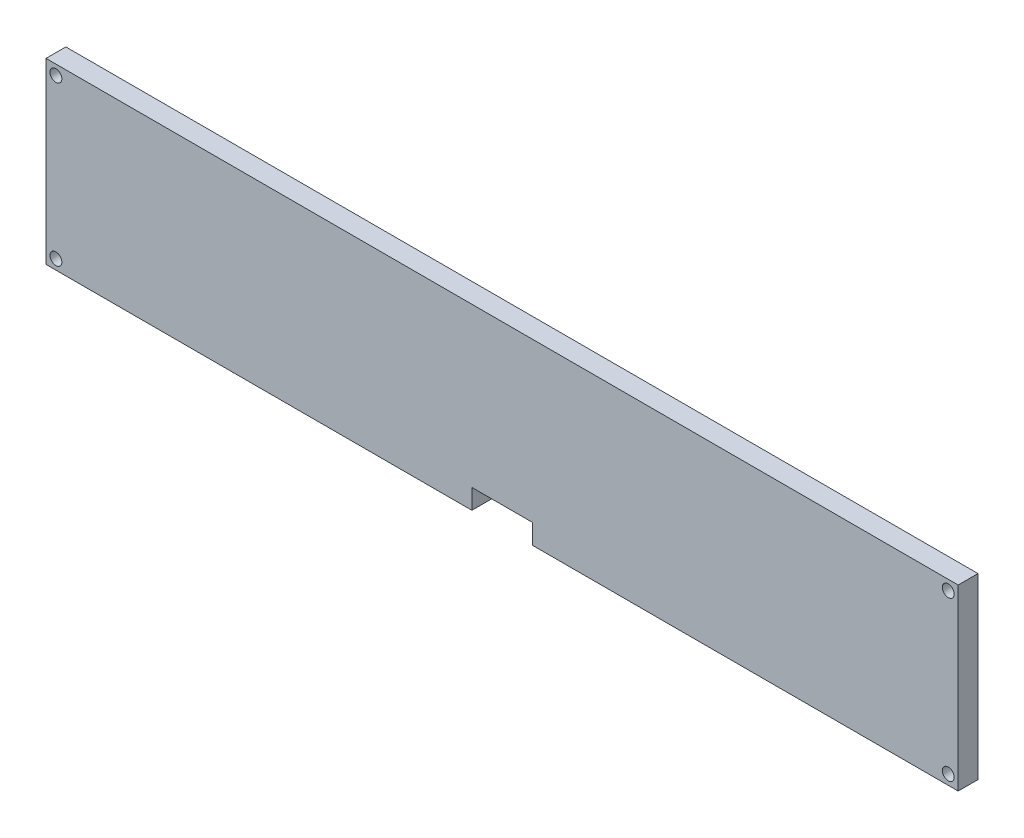
from build123d import *

# Parameters (mm, degrees)
SKETCH1_W           = 230
SKETCH1_H           = 45
BOSS_EXTRUDE1_DEPTH = 5
SKETCH2_R           = 1.5
CUT_EXTRUDE1_DEPTH  = 10
SKETCH3_W           = 15.24
SKETCH3_H           = 10
CUT_EXTRUDE2_DEPTH  = 5


with BuildPart() as part:
    # Sketch1 → Boss-Extrude1 (new body)
    with BuildSketch(Plane.XY):
        with Locations((115, 22.5)):
            Rectangle(SKETCH1_W, SKETCH1_H)
    extrude(amount=BOSS_EXTRUDE1_DEPTH)

    # Sketch2 → Cut-Extrude1 (cut)
    with BuildSketch(Plane(origin=(0, 0, 0), x_dir=(-1, 0, 0), z_dir=(0, 0, -1))):
        with Locations((-227.5, 42.5)):
            Circle(SKETCH2_R)
        with Locations((-227.5, 2.5)):
            Circle(SKETCH2_R)
        with Locations((-2.5, 2.5)):
            Circle(SKETCH2_R)
        with Locations((-2.5, 42.5)):
            Circle(SKETCH2_R)
    extrude(amount=-CUT_EXTRUDE1_DEPTH, mode=Mode.SUBTRACT)

    # Sketch3 → Cut-Extrude2 (cut)
    with BuildSketch(Plane(origin=(0, 0, 0), x_dir=(-1, 0, 0), z_dir=(0, 0, -1))):
        with Locations((-115, 0)):
            Rectangle(SKETCH3_W, SKETCH3_H)
    extrude(amount=-CUT_EXTRUDE2_DEPTH, mode=Mode.SUBTRACT)


solid = part.part
